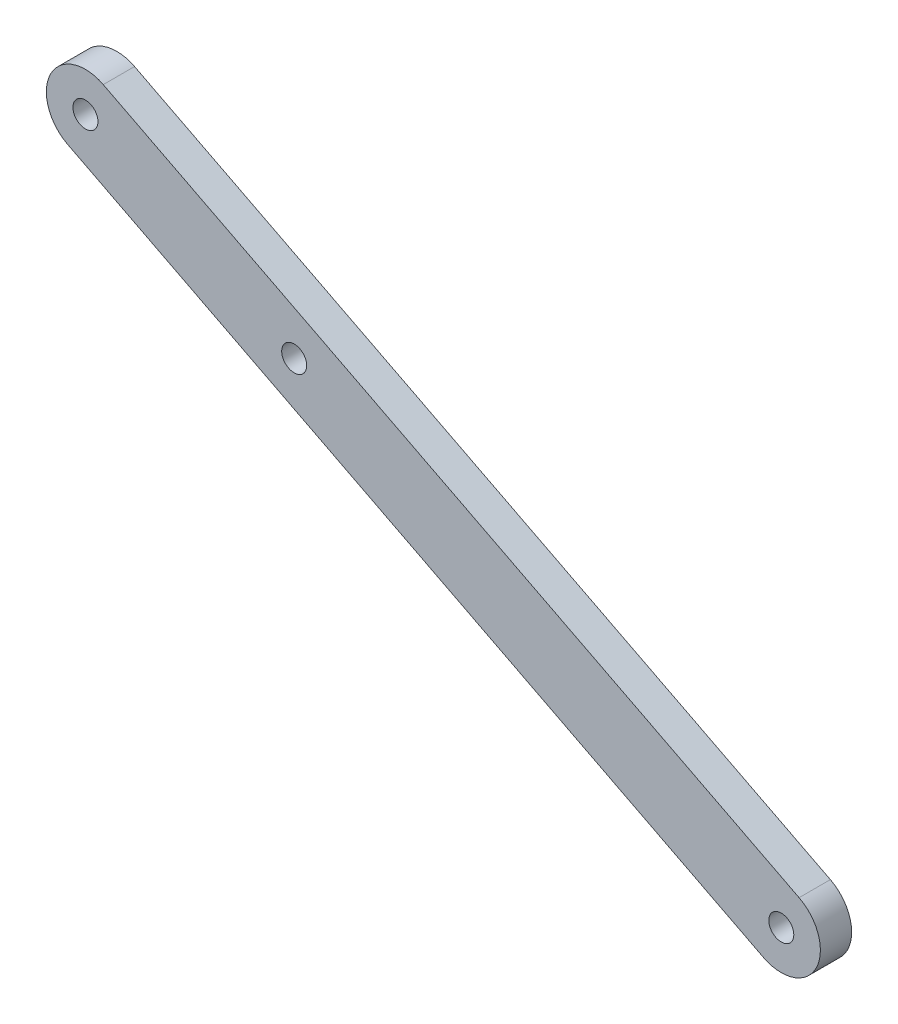
from build123d import *

# Parameters (mm, degrees)
SKETCH1_R           = 1.6
BOSS_EXTRUDE1_DEPTH = 4


with BuildPart() as part:
    # Sketch1 → Boss-Extrude1 (new body)
    with BuildSketch(Plane.XY):
        with BuildLine():
            Line((-2.278461986, -4.450686574), (-91.292193461, 41.118553149))
            ThreePointArc((-91.292193461, 41.118553149), (-93.464418049, 47.847701709), (-86.735269489, 50.019926296))
            Line((-86.735269489, 50.019926296), (2.278461986, 4.450686574))
            ThreePointArc((2.278461986, 4.450686574), (4.450686574, -2.278461986), (-2.278461986, -4.450686574))
        make_face()
        with Locations((-89.013731475, 45.569239723)):
            Circle(SKETCH1_R, mode=Mode.SUBTRACT)
        Circle(SKETCH1_R, mode=Mode.SUBTRACT)
        with Locations((-62.309612033, 31.898467806)):
            Circle(SKETCH1_R, mode=Mode.SUBTRACT)
    extrude(amount=BOSS_EXTRUDE1_DEPTH)


solid = part.part
